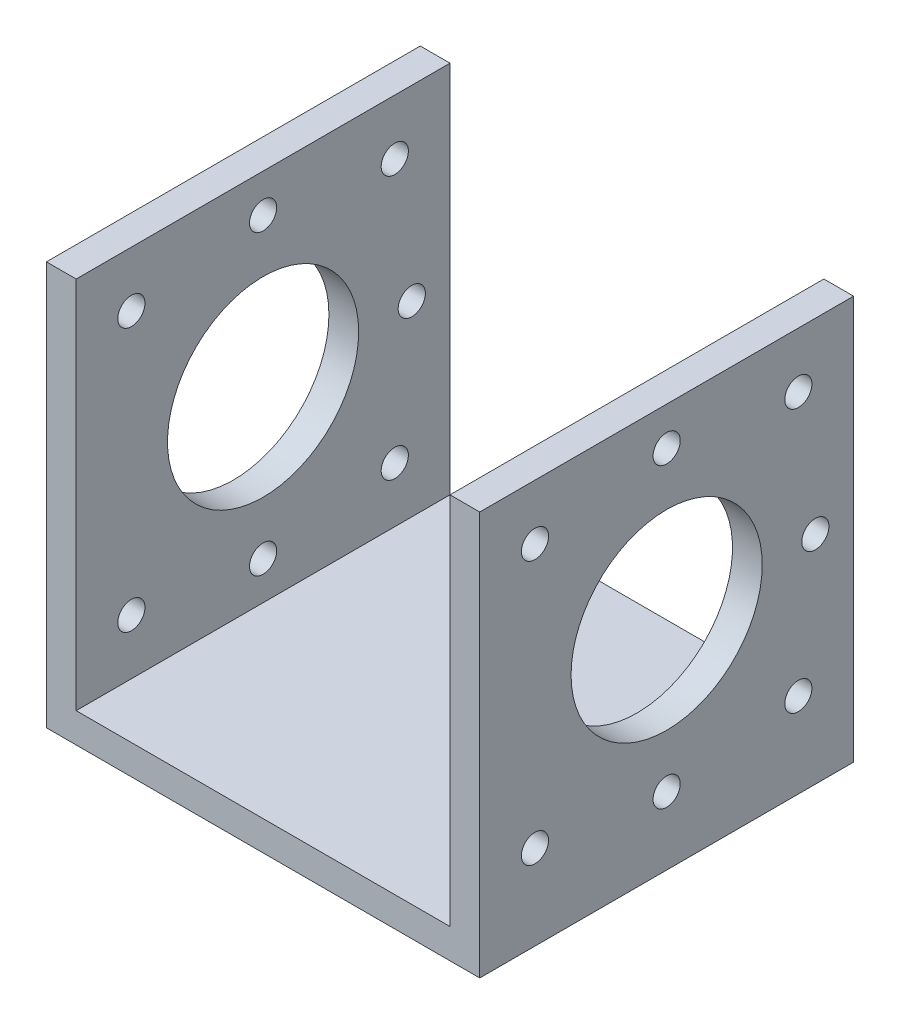
from build123d import *

# Parameters (mm, degrees)
SKETCH1_W                     = 44
SKETCH1_H                     = 44
BOSS_EXTRUDE1_DEPTH           = 3.5
SKETCH3_W                     = 3.5
SKETCH3_H                     = 44
BOSS_EXTRUDE2_DEPTH           = 44
BOSS_EXTRUDE2_DEPTH_BACK      = 3.5
SKETCH4_W                     = 3.5
SKETCH4_H                     = 44
BOSS_EXTRUDE3_DEPTH           = 44
BOSS_EXTRUDE3_DEPTH_BACK      = 3.5
SKETCH5_R                     = 11.25
CUT_EXTRUDE1_DEPTH            = 26.5
CUT_EXTRUDE1_DEPTH_BACK       = 26.5
M3_CLEARANCE_HOLE1_D          = 3.2
SKETCH16_W                    = 1.6
SKETCH16_H                    = 25.5
M3_CLEARANCE_HOLE2_AT_2_COUNT = 2
M3_CLEARANCE_HOLE2_AT_2_PITCH = 24.748737342
M3_CLEARANCE_HOLE2_AT_3_COUNT = 2
M3_CLEARANCE_HOLE2_AT_3_PITCH = 24.748737342
M3_CLEARANCE_HOLE3_D          = 3.2


with BuildPart() as part:
    # Sketch1 → Boss-Extrude1 (new body)
    with BuildSketch(Plane(origin=(0, 0, 0), x_dir=(1, 0, 0), z_dir=(0, 1, 0))):
        Rectangle(SKETCH1_W, SKETCH1_H)
    extrude(amount=-BOSS_EXTRUDE1_DEPTH)

    # Sketch3 → Boss-Extrude2 (add, two sides)
    with BuildSketch(Plane(origin=(0, 0, 0), x_dir=(1, 0, 0), z_dir=(0, 1, 0))) as boss_extrude2_sk:
        with Locations((23.75, 0)):
            Rectangle(SKETCH3_W, SKETCH3_H)
    extrude(amount=BOSS_EXTRUDE2_DEPTH)
    extrude(boss_extrude2_sk.sketch, amount=-BOSS_EXTRUDE2_DEPTH_BACK)

    # Sketch4 → Boss-Extrude3 (add, two sides)
    with BuildSketch(Plane(origin=(0, 0, 0), x_dir=(1, 0, 0), z_dir=(0, 1, 0))) as boss_extrude3_sk:
        with Locations((-23.75, 0)):
            Rectangle(SKETCH4_W, SKETCH4_H)
    extrude(amount=BOSS_EXTRUDE3_DEPTH)
    extrude(boss_extrude3_sk.sketch, amount=-BOSS_EXTRUDE3_DEPTH_BACK)

    # Sketch5 → Cut-Extrude1 (cut, two sides)
    with BuildSketch(Plane(origin=(0, 0, 0), x_dir=(0, 0, -1), z_dir=(1, 0, 0))) as cut_extrude1_sk:
        with Locations((0, 22)):
            Circle(SKETCH5_R)
    extrude(amount=CUT_EXTRUDE1_DEPTH, mode=Mode.SUBTRACT)
    extrude(cut_extrude1_sk.sketch, amount=-CUT_EXTRUDE1_DEPTH_BACK, mode=Mode.SUBTRACT)

    # M3 Clearance Hole1 (through all)
    with Locations(Plane(origin=(25.5, 0, 0), x_dir=(0, 0, -1), z_dir=(1, 0, 0))):
        with Locations((-15.5, 6.5), (-15.5, 37.5), (15.5, 37.5), (15.5, 6.5)):
            Hole(M3_CLEARANCE_HOLE1_D / 2)

    # Sketch16 → M3 Clearance Hole2 (revolve, cut)
    with BuildSketch(Plane(origin=(0, 22, -17.5), x_dir=(0, 0, 1), z_dir=(0, 1, 0))):
        with Locations((0.8, 12.75)):
            Rectangle(SKETCH16_W, SKETCH16_H)
    m3_clearance_hole2 = revolve(axis=Axis((-6.35, 22, -17.5), (1, 0, 0)), mode=Mode.SUBTRACT)

    # M3 Clearance Hole2 at 2: M3 Clearance Hole2 ×2
    with Locations(*[Vector(0, 0.707106781, 0.707106781) * (i * M3_CLEARANCE_HOLE2_AT_2_PITCH) for i in range(1, M3_CLEARANCE_HOLE2_AT_2_COUNT)]):
        add(m3_clearance_hole2, mode=Mode.SUBTRACT)

    # M3 Clearance Hole2 at 3: M3 Clearance Hole2 ×2
    with Locations(*[Vector(0, -0.707106781, 0.707106781) * (i * M3_CLEARANCE_HOLE2_AT_3_PITCH) for i in range(1, M3_CLEARANCE_HOLE2_AT_3_COUNT)]):
        add(m3_clearance_hole2, mode=Mode.SUBTRACT)

    # M3 Clearance Hole3 (through all)
    with Locations(Plane.ZY.offset(25.5)):
        with Locations((0, 4.5), (0, 39.5), (-17.5, 22)):
            Hole(M3_CLEARANCE_HOLE3_D / 2)


solid = part.part
